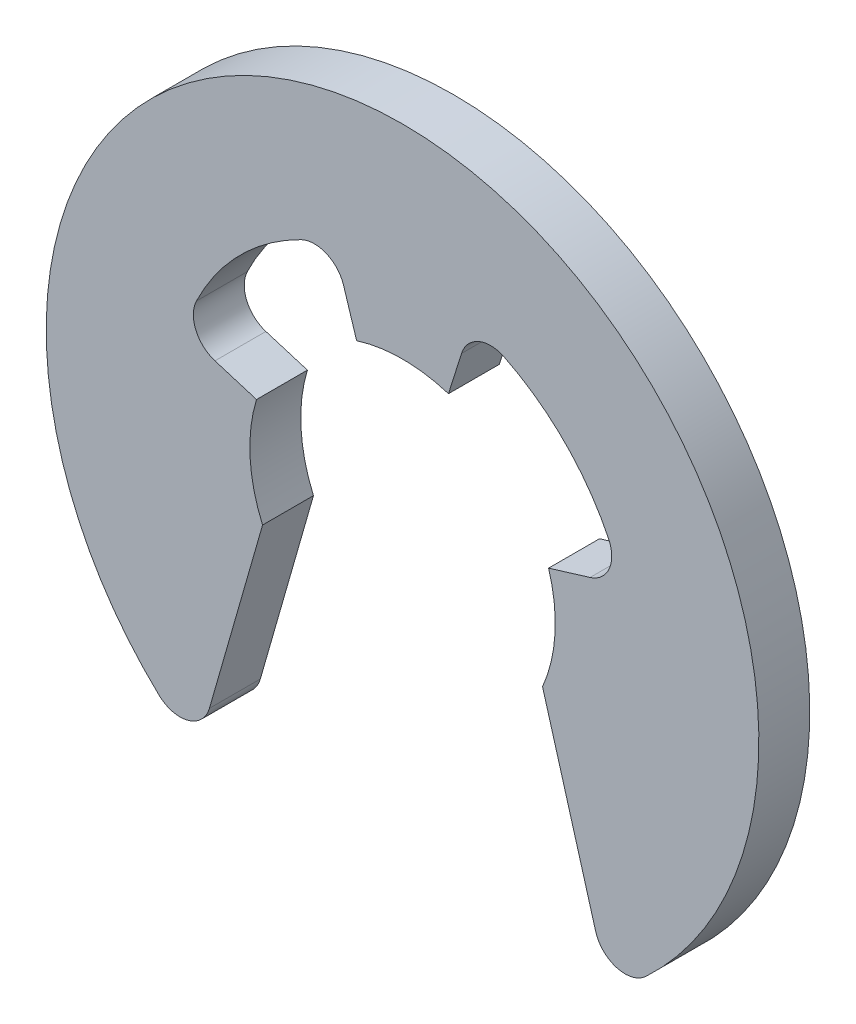
from build123d import *

# Parameters (mm, degrees)
EXTRUDE_1_DEPTH = 1


with BuildPart() as part:
    # 草图1 → 拉伸1 (new body)
    with BuildSketch(Plane.XY):
        with BuildLine():
            Line((2.75, -1.198957881), (3.794148253, -4.840335581))
            ThreePointArc((3.794148253, -4.840335581), (4.210940234, -5.253236132), (4.78067764, -5.113230026))
            ThreePointArc((4.78067764, -5.113230026), (0, 7), (-4.78067764, -5.113230026))
            ThreePointArc((-4.78067764, -5.113230026), (-4.210940234, -5.253236132), (-3.794148253, -4.840335581))
            Line((-3.794148253, -4.840335581), (-2.75, -1.198957881))
            ThreePointArc((-2.75, -1.198957881), (-2.995090843, -0.171554197), (-2.868914268, 0.877115114))
            Line((-2.868914268, 0.877115114), (-3.685187102, 1.126674764))
            ThreePointArc((-3.685187102, 1.126674764), (-4.059686231, 1.460487563), (-4.049727784, 1.962066482))
            ThreePointArc((-4.049727784, 1.962066482), (-3.19583419, 3.16806626), (-1.997331866, 4.03245154))
            ThreePointArc((-1.997331866, 4.03245154), (-1.495858948, 4.046786654), (-1.15879078, 3.675214814))
            Line((-1.15879078, 3.675214814), (-0.902117399, 2.861150852))
            ThreePointArc((-0.902117399, 2.861150852), (0, 3), (0.902117399, 2.861150852))
            Line((0.902117399, 2.861150852), (1.15879078, 3.675214814))
            ThreePointArc((1.15879078, 3.675214814), (1.495858948, 4.046786654), (1.997331866, 4.03245154))
            ThreePointArc((1.997331866, 4.03245154), (3.19583419, 3.16806626), (4.049727784, 1.962066482))
            ThreePointArc((4.049727784, 1.962066482), (4.059686231, 1.460487563), (3.685187102, 1.126674764))
            Line((3.685187102, 1.126674764), (2.868914268, 0.877115114))
            ThreePointArc((2.868914268, 0.877115114), (2.995090843, -0.171554197), (2.75, -1.198957881))
        make_face()
    extrude(amount=EXTRUDE_1_DEPTH)


solid = part.part
